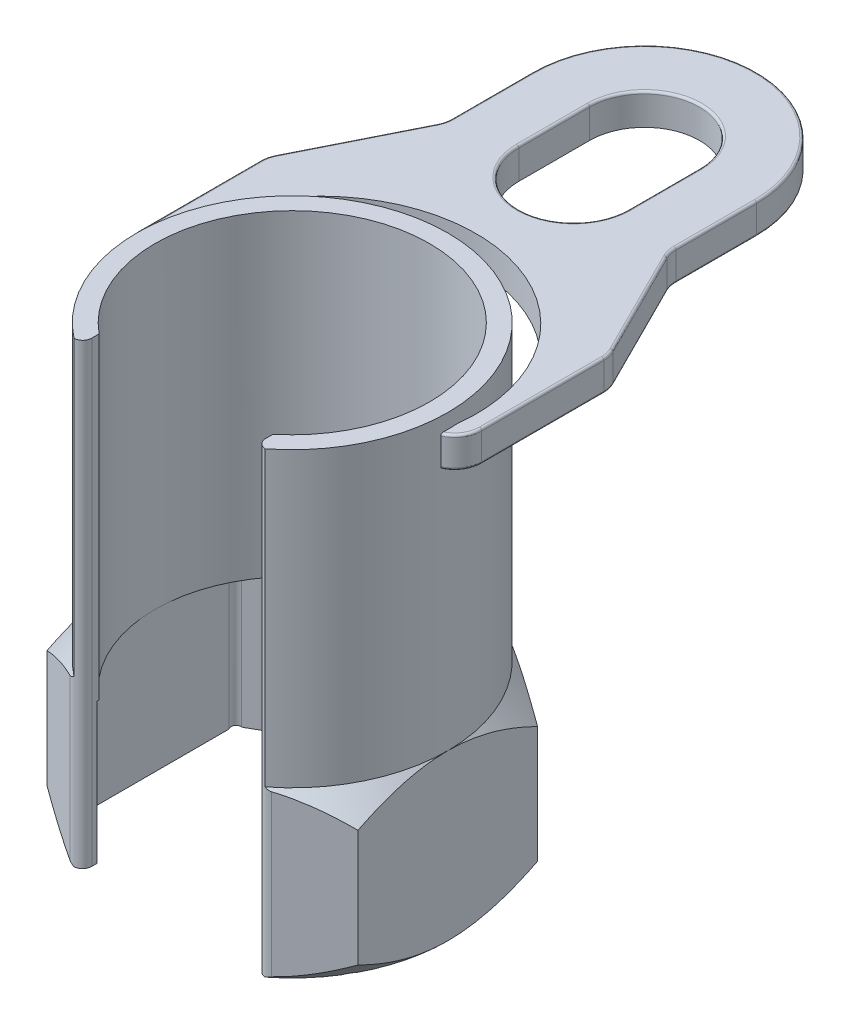
from build123d import *
from build123d.topology import SkipClean

# Parameters (mm, degrees)
EXTRUDE1_DEPTH     = 36
EXTRUDE2_DEPTH     = 64
SKETCH8_OUTSIDE_W  = 299.682
SKETCH8_OUTSIDE_H  = 299.23
SKETCH8_OUTSIDE_R  = 33.991497099
CUT_EXTRUDE4_DEPTH = 101
CUT_EXTRUDE4_DRAFT = -45
SKETCH19_OUTSIDE_W = 171.682
SKETCH19_OUTSIDE_H = 171.23
SKETCH19_OUTSIDE_R = 33.991397099
CUT_EXTRUDE6_DEPTH = 37
CUT_EXTRUDE6_DRAFT = -45
CUT_EXTRUDE9_START = -30.741397
CUT_EXTRUDE9_DEPTH = 30.741402
FILLET1_R          = 2
EXTRUDE7_DEPTH     = 6.8
CUT_EXTRUDE8_REACH = 98.8
FILLET4_R          = 0.5


with BuildPart() as part:
    # Sketch1 → Extrude1 (new body)
    with BuildSketch(Plane(origin=(0, 0, 0), x_dir=(1, 0, 0), z_dir=(0, 1, 0))):
        with BuildLine():
            Line((-19, -23.216373532), (-19, -28.280344885))
            Line((-19, -28.280344885), (-33.991497099, -19.625))
            Line((-33.991497099, -19.625), (-33.991497099, 19.625))
            Line((-33.991497099, 19.625), (0, 39.25))
            Line((0, 39.25), (33.991497099, 19.625))
            Line((33.991497099, 19.625), (33.991497099, -19.625))
            Line((33.991497099, -19.625), (19, -28.280344885))
            Line((19, -28.280344885), (19, -23.216373532))
            ThreePointArc((19, -23.216373532), (0, 30), (-19, -23.216373532))
        make_face()
    extrude(amount=EXTRUDE1_DEPTH)

    # Sketch3 → Extrude2 (add)
    with BuildSketch(Plane(origin=(0, 36, 0), x_dir=(-1, 0, 0), z_dir=(0, 1, 0))):
        with BuildLine():
            Line((-19, 28.185369906), (-19, 23.216373532))
            ThreePointArc((-19, 23.216373532), (0, -30), (19, 23.216373532))
            Line((19, 23.216373532), (19, 28.185369906))
            ThreePointArc((19, 28.185369906), (0, -33.991397099), (-19, 28.185369906))
        make_face()
    extrude(amount=EXTRUDE2_DEPTH)


with BuildPart() as cut_extrude4_tool:
    # Sketch8 outside → Cut-Extrude4 (with draft: the straight prism first)
    with BuildSketch(Plane.XZ):
        with Locations((0, -5.485)):
            Rectangle(SKETCH8_OUTSIDE_W, SKETCH8_OUTSIDE_H)
        Circle(SKETCH8_OUTSIDE_R, mode=Mode.SUBTRACT)
    extrude(amount=-CUT_EXTRUDE4_DEPTH)
    # Cut-Extrude4: the draft: its side faces are tilted about the plane it starts from
    cut_extrude4_sides = [cut_extrude4_tool.faces().sort_by_distance(p)[0] for p in [
        (0, 50.5, -155.1),
        (149.841, 50.5, -5.485),
        (0, 50.5, 144.13),
        (-149.841, 50.5, -5.485),
        (-33.991497099, 50.5, 0),
    ]]
    draft(cut_extrude4_sides, Plane.XZ, CUT_EXTRUDE4_DRAFT)


with BuildPart() as part_1:
    add(part.part)

    # Cut-Extrude4: cut by cut_extrude4_tool
    add(cut_extrude4_tool.part, mode=Mode.SUBTRACT)


with BuildPart() as cut_extrude6_tool:
    # Sketch19 outside → Cut-Extrude6 (with draft: the straight prism first)
    with BuildSketch(Plane(origin=(0, 36, 0), x_dir=(-1, 0, 0), z_dir=(0, 1, 0))):
        with Locations((0, -5.485)):
            Rectangle(SKETCH19_OUTSIDE_W, SKETCH19_OUTSIDE_H)
        Circle(SKETCH19_OUTSIDE_R, mode=Mode.SUBTRACT)
    extrude(amount=-CUT_EXTRUDE6_DEPTH)
    # Cut-Extrude6: the draft: its side faces are tilted about the plane it starts from
    cut_extrude6_sides = [cut_extrude6_tool.faces().sort_by_distance(p)[0] for p in [
        (0, 17.5, -91.1),
        (-85.841, 17.5, -5.485),
        (0, 17.5, 80.13),
        (85.841, 17.5, -5.485),
        (33.991397099, 17.5, 0),
    ]]
    draft(cut_extrude6_sides, Plane(origin=(0, 36, 0), x_dir=(-1, 0, 0), z_dir=(0, 1, 0)), CUT_EXTRUDE6_DRAFT)


with BuildPart() as part_2:
    add(part_1.part)

    # Cut-Extrude6: cut by cut_extrude6_tool
    add(cut_extrude6_tool.part, mode=Mode.SUBTRACT)

    # Sketch26 → Cut-Extrude9 (cut)
    with BuildSketch(Plane.XZ.offset(CUT_EXTRUDE9_START)):
        Polygon((-30, -17.320508076), (0, -34.641016151), (30, -17.320508076), (30, 17.320508076), (0, 34.641016151), (-30, 17.320508076), align=None)
    extrude(amount=CUT_EXTRUDE9_DEPTH, mode=Mode.SUBTRACT)

    # Fillet1
    fillet1_edges = [part_2.edges().sort_by_distance(p)[0] for p in [
        (-30, 15.695458026, -17.320508076),
        (-30, 15.695458026, 17.320508076),
        (30, 15.695458026, 17.320508076),
        (30, 15.695458026, -17.320508076),
        (-19, 17.99995, 28.280344885),
        (19, 17.99995, 28.280344885),
        (0, 15.695458026, -34.641016151),
    ]]
    fillet(fillet1_edges, radius=FILLET1_R)

    # Sketch16 → Extrude7 (add)
    with BuildSketch(Plane(origin=(0, 90, 0), x_dir=(-1, 0, 0), z_dir=(0, 1, 0))):
        with BuildLine():
            Line((-24.5, -77), (-24.5, -59.392801067))
            ThreePointArc((-24.5, -59.392801067), (-24.657830962, -58.037258836), (-25.122879573, -56.754240854))
            Line((-25.122879573, -56.754240854), (-36.877120427, -33.245759146))
            ThreePointArc((-36.877120427, -33.245759146), (-37.342169038, -31.962741164), (-37.5, -30.607198933))
            Line((-37.5, -30.607198933), (-37.5, -3.908187763))
            ThreePointArc((-37.5, -3.908187763), (-36.535781485, -0.675841689), (-33.958284361, 1.5))
            ThreePointArc((-33.958284361, 1.5), (0, -33.991397099), (33.958284361, 1.5))
            ThreePointArc((33.958284361, 1.5), (36.535781485, -0.675841689), (37.5, -3.908187763))
            Line((37.5, -3.908187763), (37.5, -30.607198933))
            ThreePointArc((37.5, -30.607198933), (37.342169038, -31.962741164), (36.877120427, -33.245759146))
            Line((36.877120427, -33.245759146), (25.122879573, -56.754240854))
            ThreePointArc((25.122879573, -56.754240854), (24.657830962, -58.037258836), (24.5, -59.392801067))
            Line((24.5, -59.392801067), (24.5, -77))
            ThreePointArc((24.5, -77), (0, -101.5), (-24.5, -77))
        make_face()
    extrude(amount=EXTRUDE7_DEPTH)

    # Sketch25 → Cut-Extrude8 (cut, up to next)
    with BuildSketch(Plane.XZ.offset(-96.8), mode=Mode.PRIVATE) as cut_extrude8_sk1:
        with BuildLine():
            Line((-12, -77), (-12, -61.5))
            ThreePointArc((-12, -61.5), (0, -49.5), (12, -61.5))
            Line((12, -61.5), (12, -77))
            ThreePointArc((12, -77), (0, -89), (-12, -77))
        make_face()
    cut_extrude8_tool1 = extrude(cut_extrude8_sk1.sketch, amount=CUT_EXTRUDE8_REACH, mode=Mode.PRIVATE) & part_2.part
    add(cut_extrude8_tool1.solids().sort_by_distance((0, 96.8, -69.25))[0], mode=Mode.SUBTRACT)
    # Sketch25 → Cut-Extrude8 (cut, up to next)
    with BuildSketch(Plane.XZ.offset(-96.8), mode=Mode.PRIVATE) as cut_extrude8_sk2:
        with BuildLine():
            ThreePointArc((33.932507669, -2), (0, -33.991397099), (-33.932507669, -2))
            ThreePointArc((-33.932507669, -2), (0, -40.167456398), (33.932507669, -2))
        make_face()
    cut_extrude8_tool2 = extrude(cut_extrude8_sk2.sketch, amount=CUT_EXTRUDE8_REACH, mode=Mode.PRIVATE) & part_2.part
    add(cut_extrude8_tool2.solids().sort_by_distance((0, 96.8, -34.774111))[0], mode=Mode.SUBTRACT)

    # Fillet4
    fillet4_edges = [part_2.edges().sort_by_distance(p)[0] for p in [
        (-36.535781485, 90, -0.675841689),
        (36.535781485, 90, -0.675841689),
        (37.5, 90, -17.257693348),
        (37.342169038, 90, -31.962741164),
        (31, 90, -45),
        (24.657830962, 90, -58.037258836),
        (24.5, 90, -68.196400534),
        (0, 90, -101.5),
        (-24.5, 90, -68.196400534),
        (-24.657830962, 90, -58.037258836),
        (-31, 90, -45),
        (-37.342169038, 90, -31.962741164),
        (-37.5, 90, -17.257693348),
        (-36.535781485, 96.8, -0.675841689),
        (36.535781485, 96.8, -0.675841689),
        (37.5, 96.8, -17.257693348),
        (37.342169038, 96.8, -31.962741164),
        (31, 96.8, -45),
        (24.657830962, 96.8, -58.037258836),
        (24.5, 96.8, -68.196400534),
        (0, 96.8, -101.5),
        (-24.5, 96.8, -68.196400534),
        (-24.657830962, 96.8, -58.037258836),
        (-31, 96.8, -45),
        (-37.342169038, 96.8, -31.962741164),
        (-37.5, 96.8, -17.257693348),
        (0, 96.8, -89),
        (12, 96.8, -69.25),
        (0, 96.8, -49.5),
        (-12, 96.8, -69.25),
    ]]
    fillet(fillet4_edges, radius=FILLET4_R)


solid = part_2.part
